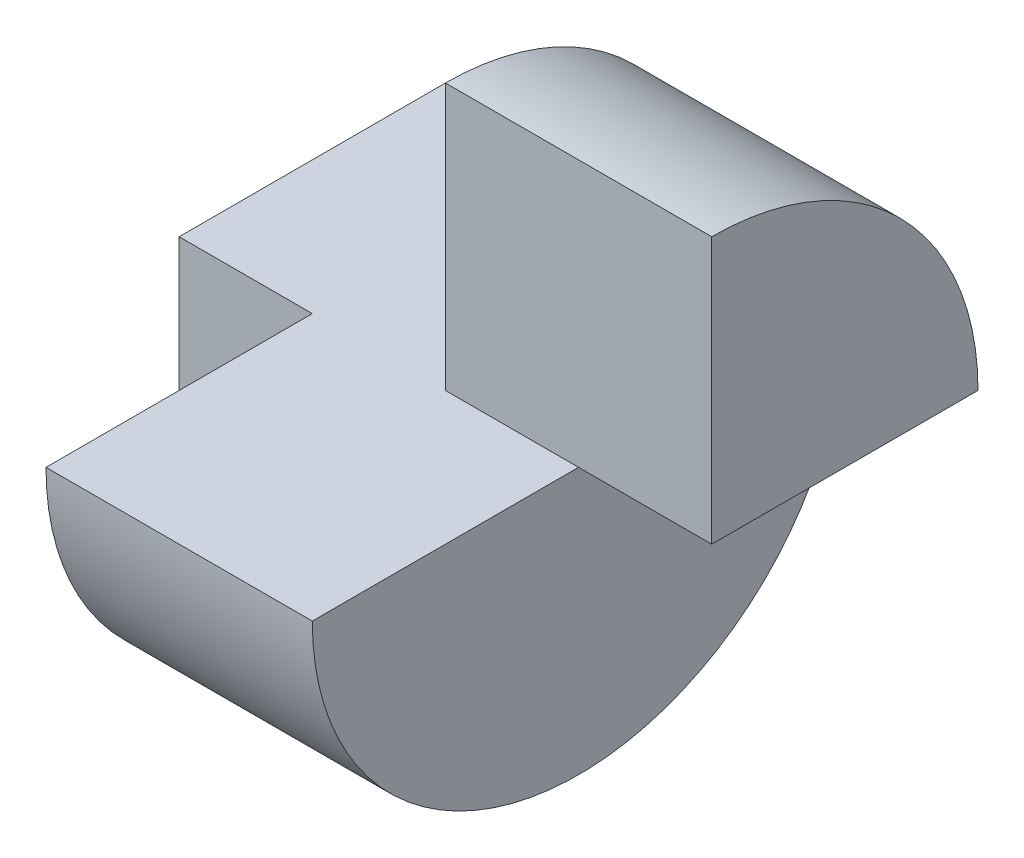
from build123d import *

# Parameters (mm, degrees)
SKETCH1_W           = 40
SKETCH1_H           = 40
BOSS_EXTRUDE1_DEPTH = 40
SKETCH2_W           = 20
SKETCH2_H           = 20
SKETCH2_W_2         = 10
CUT_EXTRUDE1_DEPTH  = 40
SKETCH3_W           = 20
SKETCH3_H           = 20
CUT_EXTRUDE2_DEPTH  = 40
CUT_EXTRUDE3_DEPTH  = 40
CUT_EXTRUDE4_DEPTH  = 40
CUT_EXTRUDE5_DEPTH  = 10


with BuildPart() as part:
    # Sketch1 → Boss-Extrude1 (new body)
    with BuildSketch(Plane.XY):
        with Locations((20, 20)):
            Rectangle(SKETCH1_W, SKETCH1_H)
    extrude(amount=BOSS_EXTRUDE1_DEPTH)

    # Sketch2 → Cut-Extrude1 (cut)
    with BuildSketch(Plane.XY.offset(40)):
        with Locations((10, 30)):
            Rectangle(SKETCH2_W, SKETCH2_H)
        with Locations((35, 10)):
            Rectangle(SKETCH2_W_2, SKETCH2_H)
    extrude(amount=-CUT_EXTRUDE1_DEPTH, mode=Mode.SUBTRACT)

    # Sketch3 → Cut-Extrude2 (cut)
    with BuildSketch(Plane.ZY.offset(-20)):
        with Locations((30, 30)):
            Rectangle(SKETCH3_W, SKETCH3_H)
    extrude(amount=-CUT_EXTRUDE2_DEPTH, mode=Mode.SUBTRACT)

    # Sketch4 → Cut-Extrude3 (cut)
    with BuildSketch(Plane.ZY.offset(-20)):
        with BuildLine():
            Line((20, 40), (0, 40))
            Line((0, 40), (0, 20))
            ThreePointArc((0, 20), (5.857864376, 34.142135624), (20, 40))
        make_face()
    extrude(amount=-CUT_EXTRUDE3_DEPTH, mode=Mode.SUBTRACT)

    # Sketch5 → Cut-Extrude4 (cut)
    with BuildSketch(Plane.ZY):
        with BuildLine():
            Line((0, 0), (20, 0))
            ThreePointArc((20, 0), (5.857864376, 5.857864376), (0, 20))
            Line((0, 20), (0, 0))
        make_face()
        with BuildLine():
            Line((40, 0), (40, 20))
            ThreePointArc((40, 20), (34.142135624, 5.857864376), (20, 0))
            Line((20, 0), (40, 0))
        make_face()
    extrude(amount=-CUT_EXTRUDE4_DEPTH, mode=Mode.SUBTRACT)

    # Sketch6 → Cut-Extrude5 (cut)
    with BuildSketch(Plane.ZY):
        with BuildLine():
            Line((20, 0), (20, 20))
            Line((20, 20), (40, 20))
            ThreePointArc((40, 20), (34.142135624, 5.857864376), (20, 0))
        make_face()
    extrude(amount=-CUT_EXTRUDE5_DEPTH, mode=Mode.SUBTRACT)


solid = part.part
